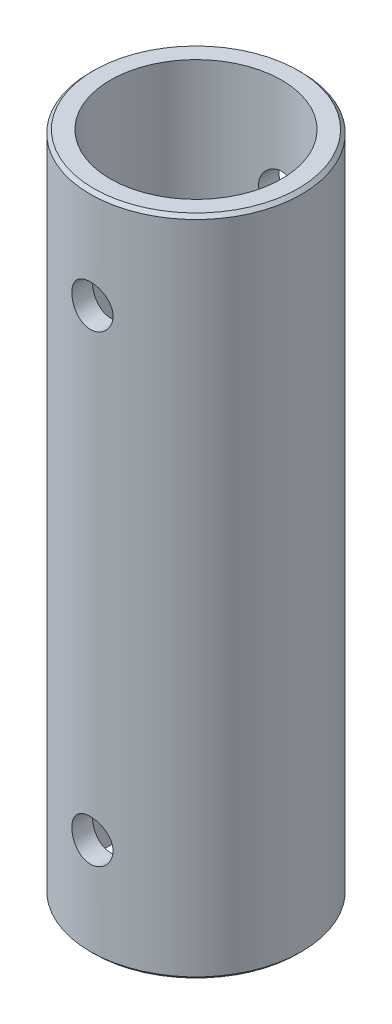
from build123d import *

# Parameters (mm, degrees)
SKETCH1_R               = 7.94
SKETCH1_R_2             = 6.44
BOSS_EXTRUDE1_DEPTH     = 49.82
CHAMFER1_SIZE           = 0.25
SKETCH2_R               = 1.55
CUT_EXTRUDE1_DEPTH      = 53.299522942
CUT_EXTRUDE1_DEPTH_BACK = 53.299522942


with BuildPart() as part:
    # Sketch1 → Boss-Extrude1 (new body)
    with BuildSketch(Plane(origin=(0, 0, 0), x_dir=(1, 0, 0), z_dir=(0, 1, 0))):
        with Locations(Location((0, 0, 0), (0, 0, 270))):
            Circle(SKETCH1_R)
        with Locations(Location((0, 0, 0), (0, 0, 270))):
            Circle(SKETCH1_R_2, mode=Mode.SUBTRACT)
    extrude(amount=BOSS_EXTRUDE1_DEPTH)

    # Chamfer1
    chamfer1_edges = [part.edges().sort_by_distance(p)[0] for p in [
        (0, 0, -7.94),
        (0, 49.82, -7.94),
    ]]
    chamfer(chamfer1_edges, length=CHAMFER1_SIZE)

    # Sketch2 → Cut-Extrude1 (cut, two sides)
    with BuildSketch(Plane(origin=(0, 0, -5.85), x_dir=(-1, 0, 0), z_dir=(0, 0, -1))) as cut_extrude1_sk:
        with Locations((0.000190227, 7.5)):
            Circle(SKETCH2_R)
        with BuildLine():
            add(Edge.make_bspline(
                [(1.550190227, 42.32), (1.550190227, 45.42), (-1.549809773, 45.42), (-1.549809773, 42.32), (-1.549809773, 39.22), (1.550190227, 39.22), (1.550190227, 42.32)],
                knots=[0, 0, 0, 0, 0.5, 0.5, 0.5, 1, 1, 1, 1], degree=3, weights=[1, 0.333333333, 0.333333333, 1, 0.333333333, 0.333333333, 1]))
        make_face()
    extrude(amount=CUT_EXTRUDE1_DEPTH, mode=Mode.SUBTRACT)
    extrude(cut_extrude1_sk.sketch, amount=-CUT_EXTRUDE1_DEPTH_BACK, mode=Mode.SUBTRACT)


solid = part.part
